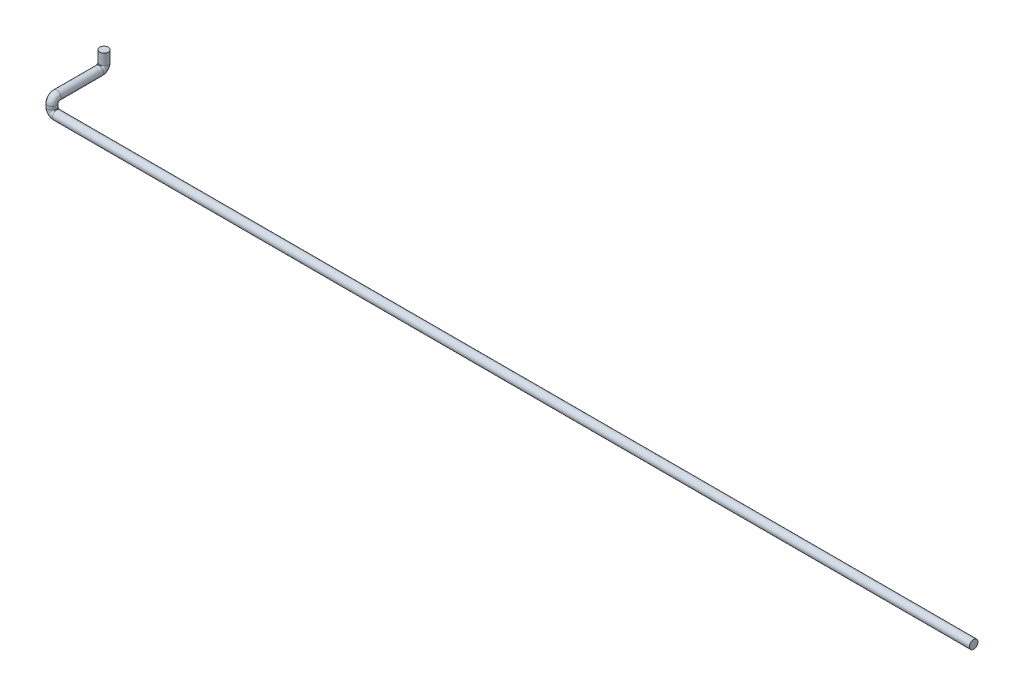
from build123d import *

# Parameters (mm, degrees)
CROQUIS1_R = 13.7


with BuildPart() as part:
    # Barrer1: sweep along a curve in space
    with BuildLine() as barrer1_path:
        Line((0, 0, 0), (-2930, 0, 0))
        ThreePointArc((-2930, 0, 0), (-2940.606601718, 4.393398282, 0), (-2945, 15, 0))
        Line((-2945, 15, 0), (-2945, 25, 0))
        ThreePointArc((-2945, 25, 0), (-2945, 35.606601718, -4.393398282), (-2945, 40, -15))
        Line((-2945, 40, -15), (-2945, 40, -151))
        ThreePointArc((-2945, 40, -151), (-2945, 44.393398282, -161.606601718), (-2945, 55, -166))
        Line((-2945, 55, -166), (-2945, 90, -166))
    # Croquis1 → Barrer1 (sweep)
    with BuildSketch(Plane(origin=(0, 0, 0), x_dir=(0, 0, -1), z_dir=(1, 0, 0))):
        Circle(CROQUIS1_R)
    sweep(path=barrer1_path.line)


solid = part.part
